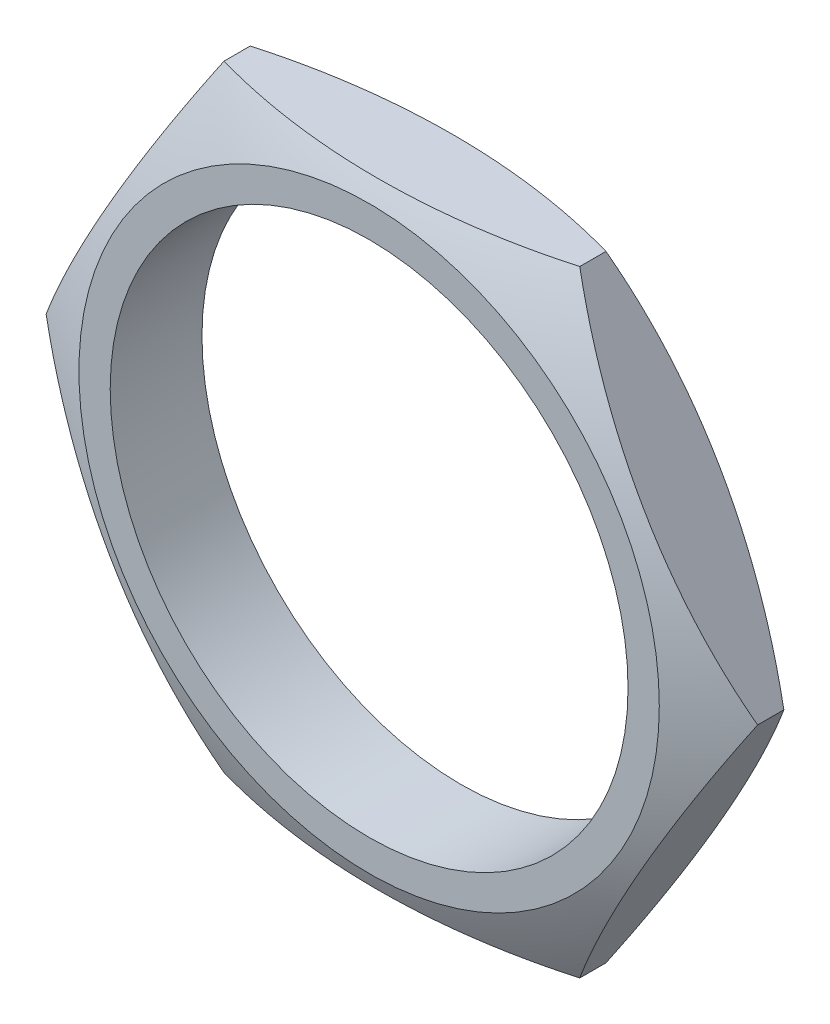
from build123d import *

# Parameters (mm, degrees)
ESQUISSE1_R        = 7.9
BOSS_EXTRU_1_DEPTH = 1.4


with BuildPart() as part:
    # Esquisse1 → Boss.-Extru.1 (new body, symmetric)
    with BuildSketch(Plane.XY):
        Polygon((10.854185061, 0), (5.42709253, 9.4), (-5.42709253, 9.4), (-10.854185061, 0), (-5.42709253, -9.4), (5.42709253, -9.4), align=None)
        Circle(ESQUISSE1_R, mode=Mode.SUBTRACT)
    extrude(amount=BOSS_EXTRU_1_DEPTH, both=True)

    # Esquisse2 → Enlèvement de matière-Révolution1 (revolve, cut)
    with BuildSketch(Plane(origin=(0, 0, 0), x_dir=(1, 0, 0), z_dir=(0, 1, 0))):
        with BuildLine():
            Line((-10.854185061, 1.4), (-10.854185061, 0.4))
            ThreePointArc((-10.854185061, 0.4), (-9.866861873, 0.925353624), (-8.854185061, 1.4))
            Line((-8.854185061, 1.4), (-10.854185061, 1.4))
        make_face()
    enl_vement_de_mati_re_r_volution1 = revolve(axis=Axis((0, 0, 0), (0, 0, -1)), mode=Mode.SUBTRACT)

    # Symétrie1: Enlèvement de matière-Révolution1 across plane
    add(enl_vement_de_mati_re_r_volution1.mirror(Plane.XY), mode=Mode.SUBTRACT)


solid = part.part
